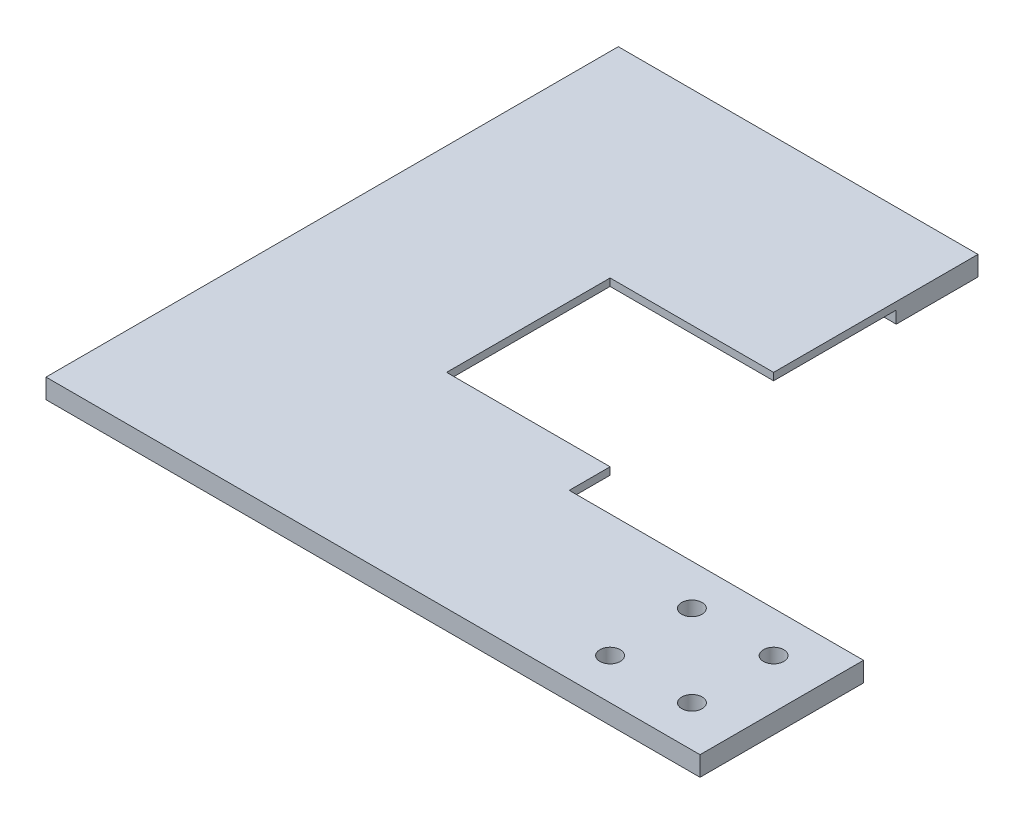
from build123d import *

# Parameters (mm, degrees)
SKETCH1_R           = 3.175
BOSS_EXTRUDE1_DEPTH = 6.096
SKETCH2_W           = 91.44
SKETCH2_H           = 152.4
CUT_EXTRUDE1_DEPTH  = 1.27
CUT_EXTRUDE2_DEPTH  = 3.81


with BuildPart() as part:
    # Sketch1 → Boss-Extrude1 (new body)
    with BuildSketch(Plane(origin=(0, 0, 0), x_dir=(1, 0, 0), z_dir=(0, 1, 0))):
        Polygon((0, 50.8), (-91.44, 50.8), (-91.44, 63.5), (-142.24, 63.5), (-142.24, 114.3), (-91.44, 114.3), (-91.44, 177.8), (-203.2, 177.8), (-203.2, 0), (0, 0), align=None)
        with Locations(Location((-15.24, 38.1, 0), (0, 0, 270))):  # turned: the seam where the file's is
            Circle(SKETCH1_R, mode=Mode.SUBTRACT)
        with Locations(Location((-40.64, 38.1, 0), (0, 0, 270))):  # turned: the seam where the file's is
            Circle(SKETCH1_R, mode=Mode.SUBTRACT)
        with Locations(Location((-40.64, 12.7, 0), (0, 0, 270))):  # turned: the seam where the file's is
            Circle(SKETCH1_R, mode=Mode.SUBTRACT)
        with Locations(Location((-15.200835983, 12.7, 0), (0, 0, 270))):  # turned: the seam where the file's is
            Circle(SKETCH1_R, mode=Mode.SUBTRACT)
    extrude(amount=-BOSS_EXTRUDE1_DEPTH)

    # Sketch2 → Cut-Extrude1 (cut)
    with BuildSketch(Plane.XZ.offset(6.096)):
        with Locations((-144.78, -88.9)):
            Rectangle(SKETCH2_W, SKETCH2_H)
    extrude(amount=-CUT_EXTRUDE1_DEPTH, mode=Mode.SUBTRACT)

    # Sketch3 → Cut-Extrude2 (cut)
    with BuildSketch(Plane.XZ.offset(6.096)):
        Polygon((-91.44, -50.8), (-94.060496217, -50.8), (-94.060496217, -25.4), (-177.8, -25.4), (-177.8, -152.4), (-91.44, -152.4), align=None)
    extrude(amount=-CUT_EXTRUDE2_DEPTH, mode=Mode.SUBTRACT)


solid = part.part
